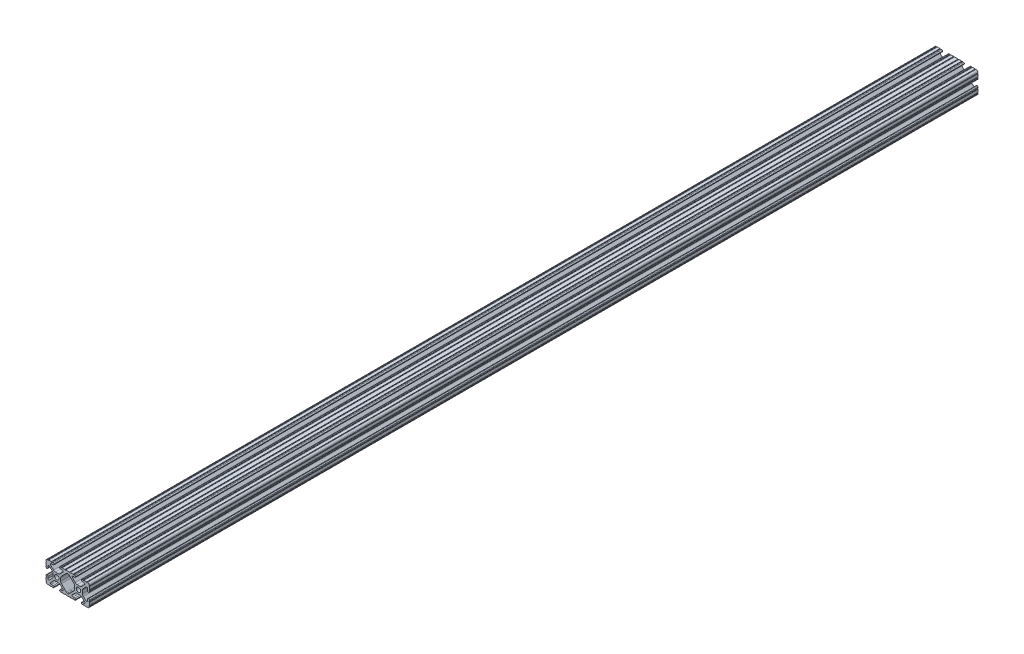
from build123d import *

# Parameters (mm, degrees)
SKETCH1_R               = 2.6035
BOSS_EXTRUDE1_DEPTH     = 520.7
SKETCH2_R               = 3.175
CUT_EXTRUDE1_DEPTH      = 9.191498123
CUT_EXTRUDE1_DEPTH_BACK = 43.608501877


with BuildPart() as part:
    # Sketch1 → Boss-Extrude1 (new body, symmetric)
    with BuildSketch(Plane.XY):
        with BuildLine():
            Line((18.01710265, 12.7), (16.98745015, 12.7))
            ThreePointArc((16.98745015, 12.7), (16.245730386, 12.392769614), (15.9385, 11.65104985))
            Line((15.9385, 11.65104985), (15.9385, 11.53922))
            ThreePointArc((15.9385, 11.53922), (16.245750844, 10.797450844), (16.98752, 10.4902))
            Line((16.98752, 10.4902), (19.116384363, 10.4902))
            ThreePointArc((19.116384363, 10.4902), (20.052502933, 9.869096983), (19.844087081, 8.765172272))
            Line((19.844087081, 8.765172272), (16.618993479, 5.455112286))
            ThreePointArc((16.618993479, 5.455112286), (15.578994274, 4.745442459), (14.344932584, 4.4958))
            Line((14.344932584, 4.4958), (11.083317835, 4.4958))
            ThreePointArc((11.083317835, 4.4958), (9.854330953, 4.743306833), (8.816955189, 5.447238587))
            Line((8.816955189, 5.447238587), (5.564154119, 8.762652677))
            ThreePointArc((5.564154119, 8.762652677), (5.352591412, 9.867473037), (6.289393385, 10.4902))
            Line((6.289393385, 10.4902), (8.41248, 10.4902))
            ThreePointArc((8.41248, 10.4902), (9.154249156, 10.797450844), (9.4615, 11.53922))
            Line((9.4615, 11.53922), (9.4615, 11.65104985))
            ThreePointArc((9.4615, 11.65104985), (9.154269614, 12.392769614), (8.41254985, 12.7))
            Line((8.41254985, 12.7), (7.38288465, 12.7))
            ThreePointArc((7.38288465, 12.7), (6.87488465, 12.192), (6.36688465, 12.7))
            Line((6.36688465, 12.7), (3.14958095, 12.7))
            ThreePointArc((3.14958095, 12.7), (2.64158095, 12.192), (2.13358095, 12.7))
            Line((2.13358095, 12.7), (-2.13358095, 12.7))
            ThreePointArc((-2.13358095, 12.7), (-2.64158095, 12.192), (-3.14958095, 12.7))
            Line((-3.14958095, 12.7), (-6.36689735, 12.7))
            ThreePointArc((-6.36689735, 12.7), (-6.87489735, 12.192), (-7.38289735, 12.7))
            Line((-7.38289735, 12.7), (-8.41254985, 12.7))
            ThreePointArc((-8.41254985, 12.7), (-9.154269614, 12.392769614), (-9.4615, 11.65104985))
            Line((-9.4615, 11.65104985), (-9.4615, 11.53922))
            ThreePointArc((-9.4615, 11.53922), (-9.154249156, 10.797450844), (-8.41248, 10.4902))
            Line((-8.41248, 10.4902), (-6.283641037, 10.4902))
            ThreePointArc((-6.283641037, 10.4902), (-5.297291557, 9.829633109), (-5.532576693, 8.666071843))
            Line((-5.532576693, 8.666071843), (-8.809985098, 5.416263103))
            ThreePointArc((-8.809985098, 5.416263103), (-9.836720513, 4.734920264), (-11.045536121, 4.4958))
            Line((-11.045536121, 4.4958), (-14.354463879, 4.4958))
            ThreePointArc((-14.354463879, 4.4958), (-15.563279487, 4.734920264), (-16.590014902, 5.416263103))
            Line((-16.590014902, 5.416263103), (-19.867423307, 8.666071843))
            ThreePointArc((-19.867423307, 8.666071843), (-20.102708443, 9.829633109), (-19.116358963, 10.4902))
            Line((-19.116358963, 10.4902), (-16.98752, 10.4902))
            ThreePointArc((-16.98752, 10.4902), (-16.245750844, 10.797450844), (-15.9385, 11.53922))
            Line((-15.9385, 11.53922), (-15.9385, 11.65104985))
            ThreePointArc((-15.9385, 11.65104985), (-16.245730386, 12.392769614), (-16.98745015, 12.7))
            Line((-16.98745015, 12.7), (-18.01711535, 12.7))
            ThreePointArc((-18.01711535, 12.7), (-18.52511535, 12.192), (-19.03311535, 12.7))
            Line((-19.03311535, 12.7), (-22.2504, 12.7))
            ThreePointArc((-22.2504, 12.7), (-22.758323491, 12.192000006), (-23.266399977, 12.699846982))
            ThreePointArc((-23.266399977, 12.699846982), (-24.782522516, 12.082522516), (-25.399846982, 10.566399977))
            ThreePointArc((-25.399846982, 10.566399977), (-24.892000006, 10.058323491), (-25.4, 9.5504))
            Line((-25.4, 9.5504), (-25.4, 6.3330836))
            ThreePointArc((-25.4, 6.3330836), (-24.892, 5.8250836), (-25.4, 5.3170836))
            Line((-25.4, 5.3170836), (-25.4, 4.237520184))
            ThreePointArc((-25.4, 4.237520184), (-25.107393763, 3.531106237), (-24.400979816, 3.2385))
            Line((-24.400979816, 3.2385), (-24.23922, 3.2385))
            ThreePointArc((-24.23922, 3.2385), (-23.497450844, 3.545750844), (-23.1902, 4.28752))
            Line((-23.1902, 4.28752), (-23.1902, 6.334741132))
            ThreePointArc((-23.1902, 6.334741132), (-22.556026952, 7.286023527), (-21.434002553, 7.066535717))
            Line((-21.434002553, 7.066535717), (-18.147950853, 3.808156468))
            ThreePointArc((-18.147950853, 3.808156468), (-17.452759693, 2.774838327), (-17.208501877, 1.553619571))
            Line((-17.208501877, 1.553619571), (-17.208501877, -1.695179196))
            ThreePointArc((-17.208501877, -1.695179196), (-17.450738657, -2.911536421), (-18.140486065, -3.942289578))
            Line((-18.140486065, -3.942289578), (-21.431579576, -7.227386226))
            ThreePointArc((-21.431579576, -7.227386226), (-22.55444896, -7.449940594), (-23.1902, -6.498002195))
            Line((-23.1902, -6.498002195), (-23.1902, -4.28752))
            ThreePointArc((-23.1902, -4.28752), (-23.497450844, -3.545750844), (-24.23922, -3.2385))
            Line((-24.23922, -3.2385), (-24.35098, -3.2385))
            ThreePointArc((-24.35098, -3.2385), (-25.092749156, -3.545750844), (-25.4, -4.28752))
            Line((-25.4, -4.28752), (-25.4, -5.3171344))
            ThreePointArc((-25.4, -5.3171344), (-24.892, -5.8251344), (-25.4, -6.3331344))
            Line((-25.4, -6.3331344), (-25.4, -9.5504))
            ThreePointArc((-25.4, -9.5504), (-24.892000006, -10.058323491), (-25.399846982, -10.566399977))
            ThreePointArc((-25.399846982, -10.566399977), (-24.782522516, -12.082522516), (-23.266399977, -12.699846982))
            ThreePointArc((-23.266399977, -12.699846982), (-22.758323491, -12.192000006), (-22.2504, -12.7))
            Line((-22.2504, -12.7), (-19.03308995, -12.7))
            ThreePointArc((-19.03308995, -12.7), (-18.52508995, -12.192), (-18.01708995, -12.7))
            Line((-18.01708995, -12.7), (-16.9874692, -12.7))
            ThreePointArc((-16.9874692, -12.7), (-16.245700044, -12.392749156), (-15.9384492, -11.65098))
            Line((-15.9384492, -11.65098), (-15.9384492, -11.53922))
            ThreePointArc((-15.9384492, -11.53922), (-16.245700044, -10.797450844), (-16.9874692, -10.4902))
            Line((-16.9874692, -10.4902), (-19.116358963, -10.4902))
            ThreePointArc((-19.116358963, -10.4902), (-20.055197748, -9.862578342), (-19.834124023, -8.755124678))
            Line((-19.834124023, -8.755124678), (-16.49660751, -5.423689618))
            ThreePointArc((-16.49660751, -5.423689618), (-15.467274017, -4.736928798), (-14.253591699, -4.4958))
            Line((-14.253591699, -4.4958), (-11.146408301, -4.4958))
            ThreePointArc((-11.146408301, -4.4958), (-9.932725983, -4.736928798), (-8.90339249, -5.423689618))
            Line((-8.90339249, -5.423689618), (-5.565875977, -8.755124678))
            ThreePointArc((-5.565875977, -8.755124678), (-5.344802252, -9.862578342), (-6.283641037, -10.4902))
            Line((-6.283641037, -10.4902), (-8.4125308, -10.4902))
            ThreePointArc((-8.4125308, -10.4902), (-9.154299956, -10.797450844), (-9.4615508, -11.53922))
            Line((-9.4615508, -11.53922), (-9.4615508, -11.65098))
            ThreePointArc((-9.4615508, -11.65098), (-9.154299956, -12.392749156), (-8.4125308, -12.7))
            Line((-8.4125308, -12.7), (-7.38287195, -12.7))
            ThreePointArc((-7.38287195, -12.7), (-6.87487195, -12.192), (-6.36687195, -12.7))
            Line((-6.36687195, -12.7), (-3.14960635, -12.7))
            ThreePointArc((-3.14960635, -12.7), (-2.64160635, -12.192), (-2.13360635, -12.7))
            Line((-2.13360635, -12.7), (2.13360635, -12.7))
            ThreePointArc((2.13360635, -12.7), (2.64159365, -12.1920127), (3.14958095, -12.7))
            Line((3.14958095, -12.7), (6.36691005, -12.7))
            ThreePointArc((6.36691005, -12.7), (6.87491005, -12.192), (7.38291005, -12.7))
            Line((7.38291005, -12.7), (8.4125308, -12.7))
            ThreePointArc((8.4125308, -12.7), (9.154299956, -12.392749156), (9.4615508, -11.65098))
            Line((9.4615508, -11.65098), (9.4615508, -11.53922))
            ThreePointArc((9.4615508, -11.53922), (9.154299956, -10.797450844), (8.4125308, -10.4902))
            Line((8.4125308, -10.4902), (6.289393385, -10.4902))
            ThreePointArc((6.289393385, -10.4902), (5.231590322, -9.783049717), (5.480677245, -8.535265862))
            Line((5.480677245, -8.535265862), (8.597933595, -5.423689618))
            ThreePointArc((8.597933595, -5.423689618), (9.627267088, -4.736928798), (10.840949406, -4.4958))
            Line((10.840949406, -4.4958), (14.102564155, -4.4958))
            ThreePointArc((14.102564155, -4.4958), (15.215927525, -4.697410182), (16.187895372, -5.276636531))
            Line((16.187895372, -5.276636531), (19.868247549, -8.482246082))
            ThreePointArc((19.868247549, -8.482246082), (20.188435806, -9.746879864), (19.116384363, -10.4902))
            Line((19.116384363, -10.4902), (16.9874692, -10.4902))
            ThreePointArc((16.9874692, -10.4902), (16.245700044, -10.797450844), (15.9384492, -11.53922))
            Line((15.9384492, -11.53922), (15.9384492, -11.65098))
            ThreePointArc((15.9384492, -11.65098), (16.245700044, -12.392749156), (16.9874692, -12.7))
            Line((16.9874692, -12.7), (18.01710265, -12.7))
            ThreePointArc((18.01710265, -12.7), (18.52510265, -12.192), (19.03310265, -12.7))
            Line((19.03310265, -12.7), (22.2504, -12.7))
            ThreePointArc((22.2504, -12.7), (22.758323491, -12.192000006), (23.266399977, -12.699846982))
            ThreePointArc((23.266399977, -12.699846982), (24.782522516, -12.082522516), (25.399846982, -10.566399977))
            ThreePointArc((25.399846982, -10.566399977), (24.892000006, -10.058323492), (25.4, -9.550400001))
            Line((25.4, -9.550400001), (25.4, -6.333083592))
            ThreePointArc((25.4, -6.333083592), (24.892000001, -5.825083593), (25.4, -5.317083593))
            Line((25.4, -5.317083593), (25.4, -4.237520184))
            ThreePointArc((25.4, -4.237520184), (25.107393763, -3.531106237), (24.400979816, -3.2385))
            Line((24.400979816, -3.2385), (24.189220184, -3.2385))
            ThreePointArc((24.189220184, -3.2385), (23.482806237, -3.531106237), (23.1902, -4.237520184))
            Line((23.1902, -4.237520184), (23.1902, -6.155876159))
            ThreePointArc((23.1902, -6.155876159), (22.62232736, -7.038258539), (21.583974541, -6.886926384))
            Line((21.583974541, -6.886926384), (18.29817066, -4.024970844))
            ThreePointArc((18.29817066, -4.024970844), (17.493730985, -2.946044689), (17.208501877, -1.630807374))
            Line((17.208501877, -1.630807374), (17.208501877, 1.630807374))
            ThreePointArc((17.208501877, 1.630807374), (17.442348332, 2.82673414), (18.109440981, 3.846495088))
            Line((18.109440981, 3.846495088), (21.526346532, 7.353420386))
            ThreePointArc((21.526346532, 7.353420386), (22.585896263, 7.574939077), (23.1902, 6.676867167))
            Line((23.1902, 6.676867167), (23.1902, 4.237520184))
            ThreePointArc((23.1902, 4.237520184), (23.482806237, 3.531106237), (24.189220184, 3.2385))
            Line((24.189220184, 3.2385), (24.400979816, 3.2385))
            ThreePointArc((24.400979816, 3.2385), (25.107393763, 3.531106237), (25.4, 4.237520184))
            Line((25.4, 4.237520184), (25.4, 5.3170836))
            ThreePointArc((25.4, 5.3170836), (24.891949193, 5.825134407), (25.4, 6.333185215))
            Line((25.4, 6.333185215), (25.4, 9.550400015))
            ThreePointArc((25.4, 9.550400015), (24.892000013, 10.058323498), (25.399846982, 10.566399977))
            ThreePointArc((25.399846982, 10.566399977), (24.782522516, 12.082522516), (23.266399977, 12.699846982))
            ThreePointArc((23.266399977, 12.699846982), (22.758323491, 12.192000006), (22.2504, 12.7))
            Line((22.2504, 12.7), (19.03310265, 12.7))
            ThreePointArc((19.03310265, 12.7), (18.52510265, 12.192), (18.01710265, 12.7))
        make_face()
        with Locations((-12.7, 0)):
            Circle(SKETCH1_R, mode=Mode.SUBTRACT)
        with Locations((12.7, 0)):
            Circle(SKETCH1_R, mode=Mode.SUBTRACT)
        with BuildLine():
            Line((-7.259513935, -3.869413038), (-1.545748891, -9.572766749))
            ThreePointArc((-1.545748891, -9.572766749), (-1.035199478, -9.913400116), (-0.433213048, -10.033))
            Line((-0.433213048, -10.033), (0.433213048, -10.033))
            ThreePointArc((0.433213048, -10.033), (1.035199478, -9.913400116), (1.545748891, -9.572766749))
            Line((1.545748891, -9.572766749), (7.259513935, -3.869413038))
            ThreePointArc((7.259513935, -3.869413038), (7.949261343, -2.838659881), (8.191498123, -1.622302656))
            Line((8.191498123, -1.622302656), (8.191498123, 1.622302656))
            ThreePointArc((8.191498123, 1.622302656), (7.955573352, 2.823327967), (7.282860769, 3.845864069))
            Line((7.282860769, 3.845864069), (1.675572808, 9.561086461))
            ThreePointArc((1.675572808, 9.561086461), (1.161034429, 9.910236611), (0.551456936, 10.033))
            Line((0.551456936, 10.033), (-0.395199982, 10.033))
            ThreePointArc((-0.395199982, 10.033), (-0.994772524, 9.914396349), (-1.50403329, 9.576450301))
            Line((-1.50403329, 9.576450301), (-7.252049147, 3.876839553))
            ThreePointArc((-7.252049147, 3.876839553), (-7.947240307, 2.843521412), (-8.191498123, 1.622302656))
            Line((-8.191498123, 1.622302656), (-8.191498123, -1.622302656))
            ThreePointArc((-8.191498123, -1.622302656), (-7.949261343, -2.838659881), (-7.259513935, -3.869413038))
        make_face(mode=Mode.SUBTRACT)
    extrude(amount=BOSS_EXTRUDE1_DEPTH, both=True)

    # Sketch2 → Cut-Extrude1 (cut, two sides)
    with BuildSketch(Plane(origin=(17.208501877, 0, 0), x_dir=(0, 0, -1), z_dir=(1, 0, 0))) as cut_extrude1_sk:
        with Locations((508, 0)):
            Circle(SKETCH2_R)
        with Locations((-508, 0)):
            Circle(SKETCH2_R)
    extrude(amount=CUT_EXTRUDE1_DEPTH, mode=Mode.SUBTRACT)
    extrude(cut_extrude1_sk.sketch, amount=-CUT_EXTRUDE1_DEPTH_BACK, mode=Mode.SUBTRACT)


solid = part.part
